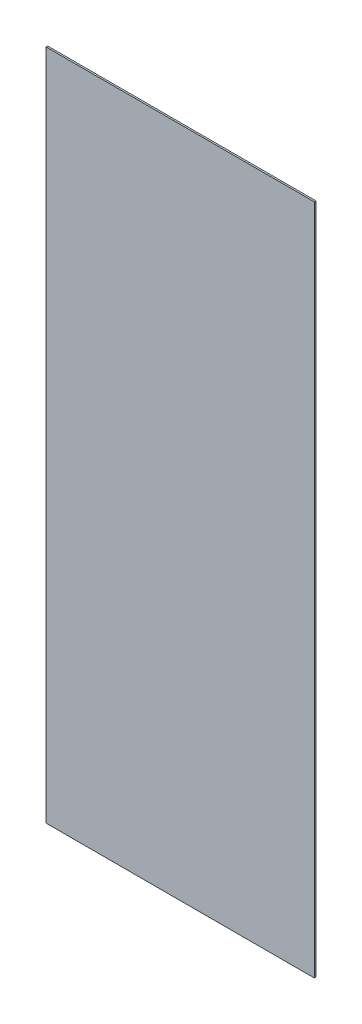
from build123d import *

# Parameters (mm, degrees)
SKETCH1_W           = 164
SKETCH1_H           = 411
BOSS_EXTRUDE1_DEPTH = 1


with BuildPart() as part:
    # Sketch1 → Boss-Extrude1 (new body)
    with BuildSketch(Plane.XY):
        with Locations((21.516129032, 110.376935862)):
            Rectangle(SKETCH1_W, SKETCH1_H)
    extrude(amount=BOSS_EXTRUDE1_DEPTH)


solid = part.part
